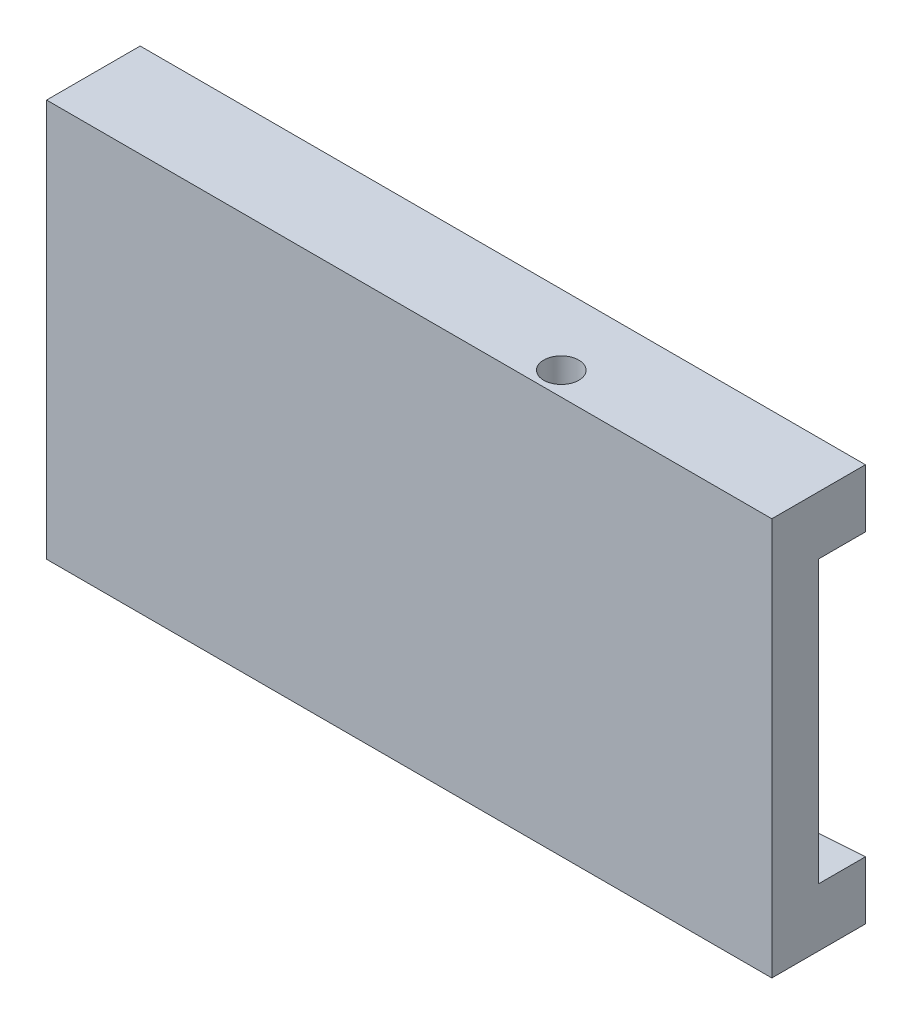
from build123d import *

# Parameters (mm, degrees)
SKETCH1_W           = 40
SKETCH1_H           = 4
BOSS_EXTRUDE1_DEPTH = 34
SKETCH2_R           = 1.5
CUT_EXTRUDE1_DEPTH  = 6
SKETCH3_W           = 4
SKETCH3_H           = 34
BOSS_EXTRUDE2_DEPTH = 22
BOSS_EXTRUDE3_DEPTH = 4


with BuildPart() as part:
    # Sketch1 → Boss-Extrude1 (new body)
    with BuildSketch(Plane(origin=(0, 0, 0), x_dir=(1, 0, 0), z_dir=(0, 1, 0))):
        Rectangle(SKETCH1_W, SKETCH1_H)
    extrude(amount=BOSS_EXTRUDE1_DEPTH)

    # Sketch2 → Cut-Extrude1 (cut)
    with BuildSketch(Plane.XZ):
        Circle(SKETCH2_R)
    cut_extrude1 = extrude(amount=-CUT_EXTRUDE1_DEPTH, mode=Mode.SUBTRACT)

    # Mirror1: Cut-Extrude1 across plane
    add(cut_extrude1.mirror(Plane(origin=(0, 17, 0), x_dir=(0, 0, 1), z_dir=(0, -1, 0))), mode=Mode.SUBTRACT)

    # Sketch3 → Boss-Extrude2 (add)
    with BuildSketch(Plane.ZY.offset(20)):
        with Locations((0, 17)):
            Rectangle(SKETCH3_W, SKETCH3_H)
    extrude(amount=BOSS_EXTRUDE2_DEPTH)

    # Sketch5 → Boss-Extrude3 (add)
    with BuildSketch(Plane(origin=(0, 0, -2), x_dir=(-1, 0, 0), z_dir=(0, 0, -1))):
        Polygon((-20, 29.024641929), (42, 33), (42, 34), (-20, 34), align=None)
        Polygon((42, 0), (-20, 0), (-20, 4.975358071), (42, 1), align=None)
    extrude(amount=BOSS_EXTRUDE3_DEPTH)


solid = part.part
